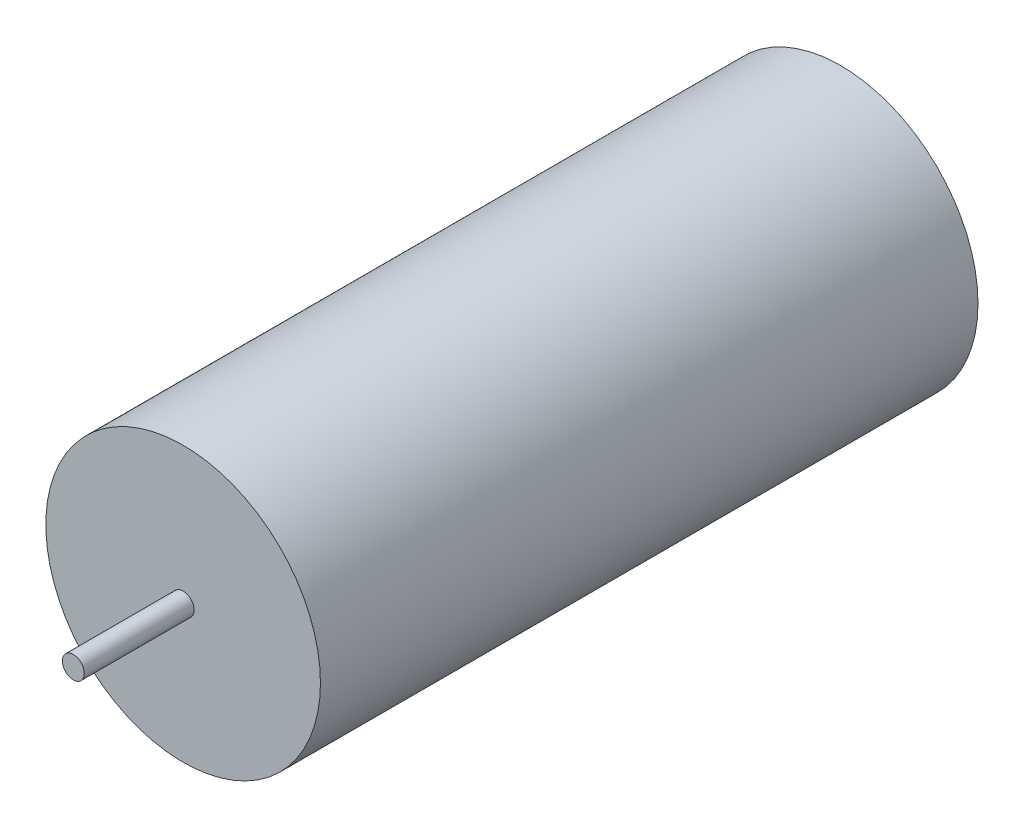
from build123d import *

# Parameters (mm, degrees)
SKETCH1_R           = 12.5
BOSS_EXTRUDE1_DEPTH = 59.86
SKETCH2_R           = 1
BOSS_EXTRUDE2_DEPTH = 10


with BuildPart() as part:
    # Sketch1 → Boss-Extrude1 (new body)
    with BuildSketch(Plane.XY):
        Circle(SKETCH1_R)
    extrude(amount=BOSS_EXTRUDE1_DEPTH)

    # Sketch2 → Boss-Extrude2 (add)
    with BuildSketch(Plane.XY.offset(59.86)):
        Circle(SKETCH2_R)
    extrude(amount=BOSS_EXTRUDE2_DEPTH)


solid = part.part
